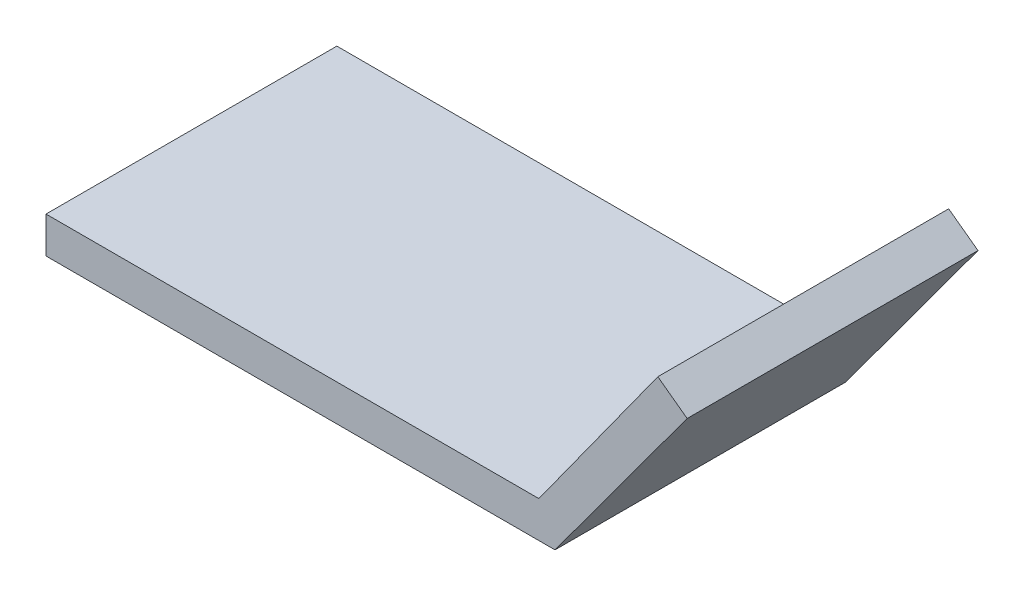
from build123d import *

# Parameters (mm, degrees)
BOSS_EXTRUDE1_DEPTH = 25.4


with BuildPart() as part:
    # Sketch1 → Boss-Extrude1 (new body)
    with BuildSketch(Plane.XY):
        Polygon((0, 0), (-44.45, 0), (-44.45, 3.175), (-1.408040596, 3.175), (8.980816396, 17.587358464), (11.539547466, 15.707592438), align=None)
    extrude(amount=BOSS_EXTRUDE1_DEPTH)


solid = part.part
